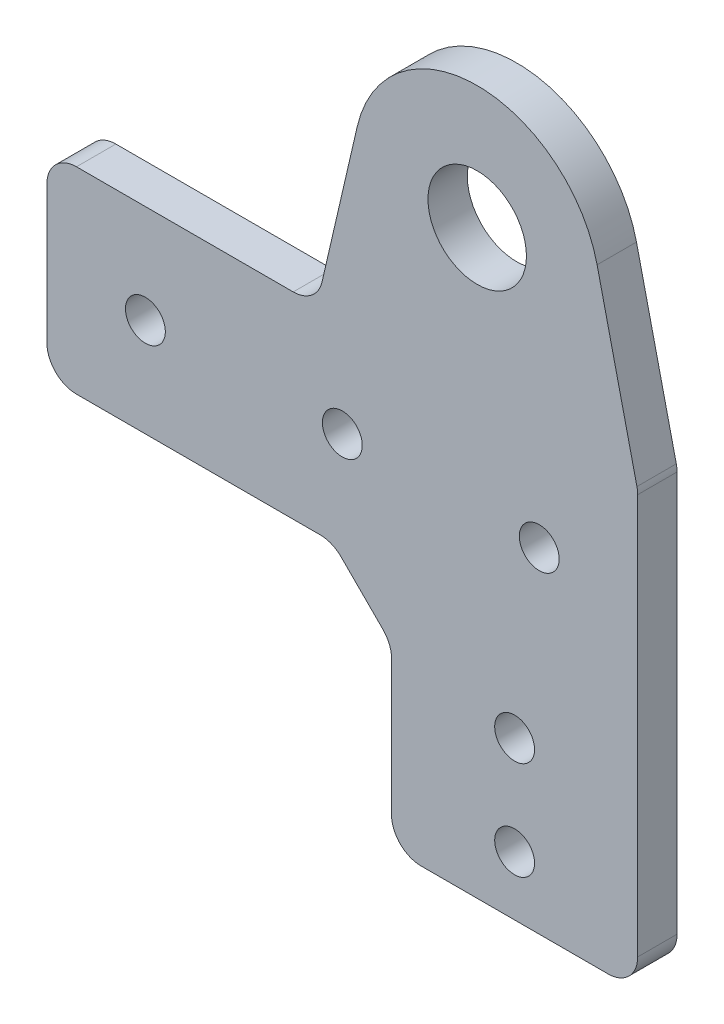
from build123d import *

# Parameters (mm, degrees)
EXTRUDE_1_DEPTH          = 4
EXTRUDE_2_DEPTH          = 4
SKETCH_3_R               = 5
CUT_EXTRUDE_1_DEPTH      = 4
SKETCH_6_W               = 25
SKETCH_6_H               = 6
CUT_EXTRUDE_4_DEPTH      = 1
CUT_EXTRUDE_4_DEPTH_BACK = 5
SKETCH_7_R               = 2.025
CUT_EXTRUDE_5_DEPTH      = 1
CUT_EXTRUDE_5_DEPTH_BACK = 5
SKETCH_9_R               = 5
EXTRUDE_3_DEPTH          = 4
SKETCH_12_R              = 2.025
CUT_EXTRUDE_8_DEPTH      = 1
CUT_EXTRUDE_8_DEPTH_BACK = 5
EXTRUDE_4_DEPTH          = 4
FILLET_1_R               = 3


with BuildPart() as part:
    # 草图1 → 凸台-拉伸1 (new body)
    with BuildSketch(Plane.XY):
        Polygon((-35, 0), (0, 0), (0, -30), (25, -30), (25, 20), (-35, 20), align=None)
    extrude(amount=EXTRUDE_1_DEPTH)

    # 草图2 → 凸台-拉伸2 (add)
    with BuildSketch(Plane(origin=(0, 0, 0), x_dir=(-1, 0, 0), z_dir=(0, 0, -1))):
        with BuildLine():
            Line((-15.347247215, 38.473341973), (-25, 20))
            Line((-25, 20), (7.6, 20))
            Line((7.6, 20), (-2.052752785, 38.473341973))
            ThreePointArc((-2.052752785, 38.473341973), (-8.7, 42.5), (-15.347247215, 38.473341973))
        make_face()
    extrude(amount=-EXTRUDE_2_DEPTH)

    # 草图3 → 切除-拉伸1 (cut)
    with BuildSketch(Plane(origin=(0, 0, 0), x_dir=(-1, 0, 0), z_dir=(0, 0, -1))):
        with Locations((-8.7, 35)):
            Circle(SKETCH_3_R)
    extrude(amount=-CUT_EXTRUDE_1_DEPTH, mode=Mode.SUBTRACT)

    # 草图6 → 切除-拉伸4 (cut, two sides)
    with BuildSketch(Plane(origin=(0, 0, 0), x_dir=(-1, 0, 0), z_dir=(0, 0, -1))) as cut_extrude_4_sk:
        with Locations((-12.5, -27)):
            Rectangle(SKETCH_6_W, SKETCH_6_H)
    extrude(amount=CUT_EXTRUDE_4_DEPTH, mode=Mode.SUBTRACT)
    extrude(cut_extrude_4_sk.sketch, amount=-CUT_EXTRUDE_4_DEPTH_BACK, mode=Mode.SUBTRACT)

    # 草图7 → 切除-拉伸5 (cut, two sides)
    with BuildSketch(Plane(origin=(0, 0, 0), x_dir=(-1, 0, 0), z_dir=(0, 0, -1))) as cut_extrude_5_sk:
        with Locations((-12.5, -8)):
            Circle(SKETCH_7_R)
        with Locations((-12.5, -18)):
            Circle(SKETCH_7_R)
    extrude(amount=CUT_EXTRUDE_5_DEPTH, mode=Mode.SUBTRACT)
    extrude(cut_extrude_5_sk.sketch, amount=-CUT_EXTRUDE_5_DEPTH_BACK, mode=Mode.SUBTRACT)

    # 草图9 → 凸台-拉伸3 (add)
    with BuildSketch(Plane(origin=(0, 0, 0), x_dir=(-1, 0, 0), z_dir=(0, 0, -1))):
        with BuildLine():
            Line((-20.878399595, 37.817194226), (-25, 20))
            Line((-25, 20), (7.6, 20))
            Line((7.6, 20), (3.478399595, 37.817194226))
            ThreePointArc((3.478399595, 37.817194226), (-8.7, 47.5), (-20.878399595, 37.817194226))
        make_face()
        with Locations((-8.7, 35)):
            Circle(SKETCH_9_R, mode=Mode.SUBTRACT)
    extrude(amount=-EXTRUDE_3_DEPTH)

    # 草图12 → 切除-拉伸8 (cut, two sides)
    with BuildSketch(Plane(origin=(0, 0, 0), x_dir=(-1, 0, 0), z_dir=(0, 0, -1))) as cut_extrude_8_sk:
        with Locations((-15, 10)):
            Circle(SKETCH_12_R)
        with Locations((5, 10)):
            Circle(SKETCH_12_R)
        with Locations((25, 10)):
            Circle(SKETCH_12_R)
    extrude(amount=CUT_EXTRUDE_8_DEPTH, mode=Mode.SUBTRACT)
    extrude(cut_extrude_8_sk.sketch, amount=-CUT_EXTRUDE_8_DEPTH_BACK, mode=Mode.SUBTRACT)

    # 草图13 → 凸台-拉伸4 (add)
    with BuildSketch(Plane(origin=(0, 0, 0), x_dir=(-1, 0, 0), z_dir=(0, 0, -1))):
        Polygon((0, -6), (6, 0), (0, 0), align=None)
    extrude(amount=-EXTRUDE_4_DEPTH)

    # 圆角1
    fillet_1_edges = [part.edges().sort_by_distance(p)[0] for p in [
        (-6, 0, 2),
        (0, -6, 2),
        (-35, 20, 2),
        (25, 20, 2),
        (-35, 0, 2),
        (-7.6, 20, 2),
        (25, -24, 2),
        (0, -24, 2),
    ]]
    fillet(fillet_1_edges, radius=FILLET_1_R)


solid = part.part
